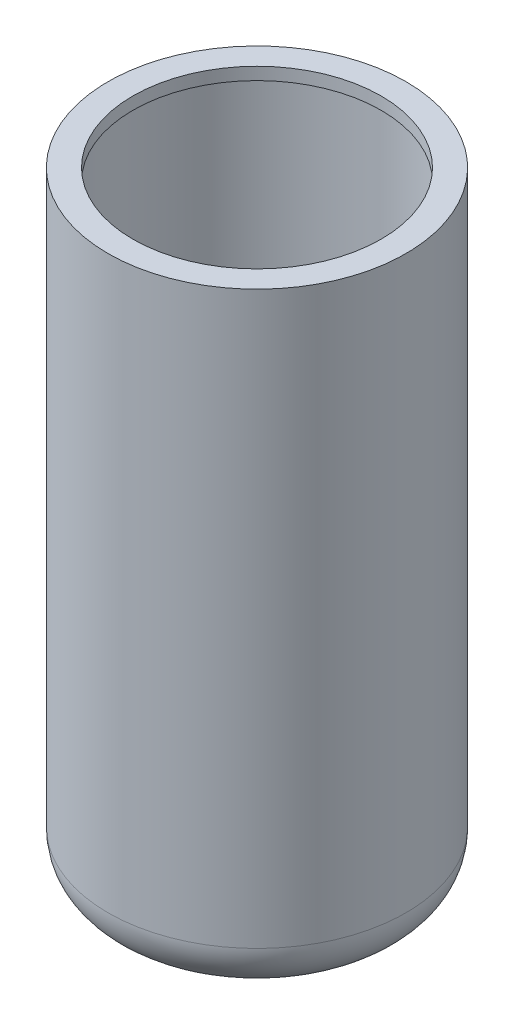
from build123d import *

# Parameters (mm, degrees)
SKETCH3_W           = 15.24
SKETCH3_H           = 63.5
FILLET5_R           = 5.08
SHELL5_T            = -1.27
SKETCH9_R           = 13.97
SKETCH9_R_2         = 12.7
BOSS_EXTRUDE5_DEPTH = 1.27


with BuildPart() as part:
    # Sketch3 → Revolve1 (revolve)
    with BuildSketch(Plane(origin=(0, 0, 0), x_dir=(0, 0, -1), z_dir=(1, 0, 0))):
        with Locations((7.62, 31.75)):
            Rectangle(SKETCH3_W, SKETCH3_H)
    revolve(axis=Axis((0, 0, 0), (0, 1, 0)))

    # Fillet5
    fillet5_edges = [part.edges().sort_by_distance(p)[0] for p in [
        (0, 0, 15.24),
    ]]
    fillet(fillet5_edges, radius=FILLET5_R)

    # Shell5
    shell5_openings = [part.faces().sort_by_distance(p)[0] for p in [
        (0, 63.5, 0),
    ]]
    offset(amount=SHELL5_T, openings=shell5_openings, kind=Kind.INTERSECTION)

    # Sketch9 → Boss-Extrude5 (add)
    with BuildSketch(Plane(origin=(0, 63.5, 0), x_dir=(1, 0, 0), z_dir=(0, 1, 0))):
        with Locations(Location((0, 0, 0), (0, 0, 90))):
            Circle(SKETCH9_R)
        with Locations(Location((0, 0, 0), (0, 0, 270))):
            Circle(SKETCH9_R_2, mode=Mode.SUBTRACT)
    extrude(amount=-BOSS_EXTRUDE5_DEPTH)


solid = part.part
